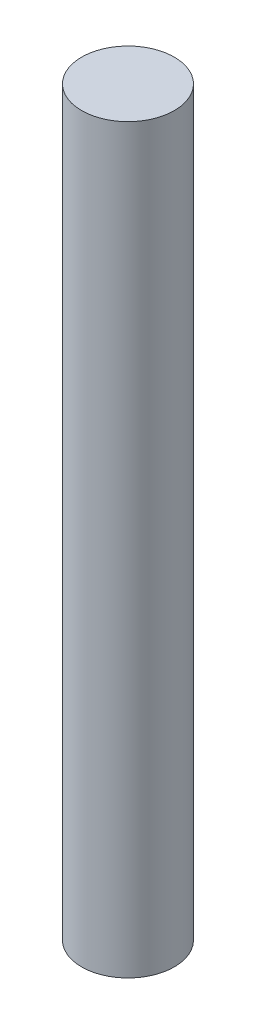
from build123d import *

# Parameters (mm, degrees)
CROQUIS1_R              = 4.7625
SALIENTE_EXTRUIR1_DEPTH = 76.2


with BuildPart() as part:
    # Croquis1 → Saliente-Extruir1 (new body)
    with BuildSketch(Plane(origin=(0, 0, 0), x_dir=(1, 0, 0), z_dir=(0, 1, 0))):
        Circle(CROQUIS1_R)
    extrude(amount=SALIENTE_EXTRUIR1_DEPTH)


solid = part.part
